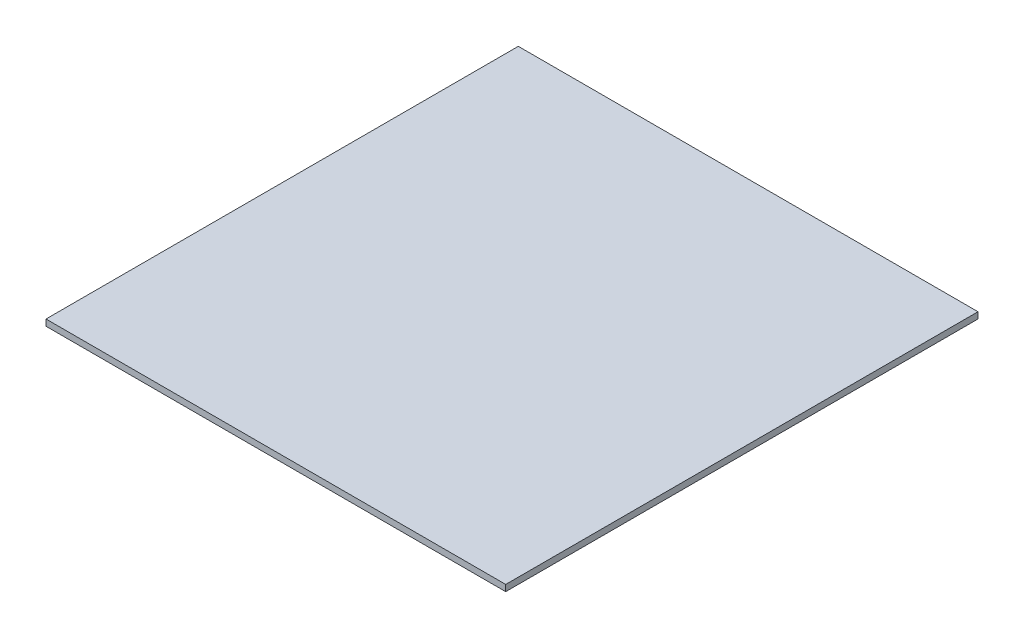
from build123d import *

# Parameters (mm, degrees)
SKETCH1_W           = 146
SKETCH1_H           = 2
BOSS_EXTRUDE1_DEPTH = 150


with BuildPart() as part:
    # Sketch1 → Boss-Extrude1 (new body)
    with BuildSketch(Plane.XY):
        with Locations((0, -74)):
            Rectangle(SKETCH1_W, SKETCH1_H)
    extrude(amount=BOSS_EXTRUDE1_DEPTH)


solid = part.part
